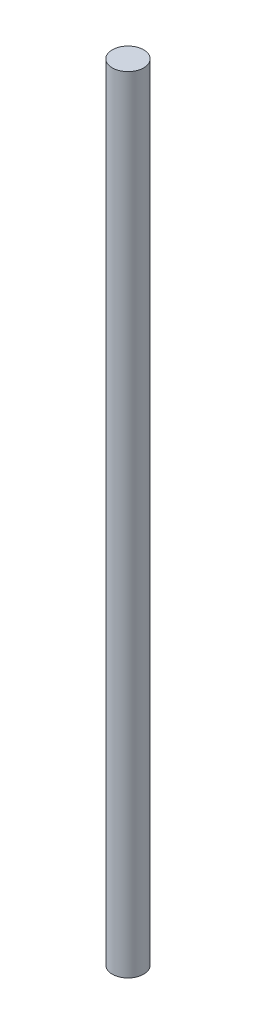
from build123d import *

# Parameters (mm, degrees)
SKETCH1_R           = 2
BOSS_EXTRUDE1_DEPTH = 100


with BuildPart() as part:
    # Sketch1 → Boss-Extrude1 (new body)
    with BuildSketch(Plane(origin=(0, 0, 0), x_dir=(1, 0, 0), z_dir=(0, 1, 0))):
        Circle(SKETCH1_R)
    extrude(amount=BOSS_EXTRUDE1_DEPTH)


solid = part.part
